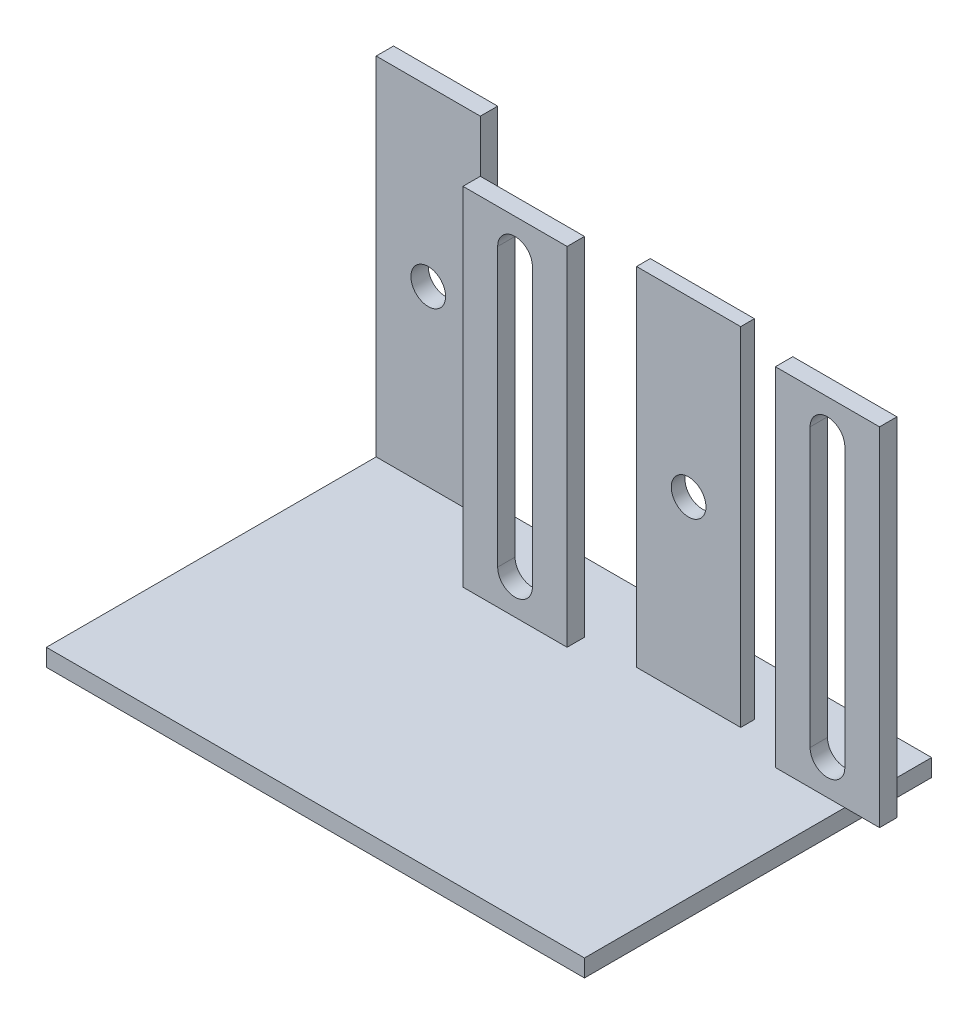
from build123d import *

# Parameters (mm, degrees)
SKETCH1_W           = 310
SKETCH1_H           = 200
BOSS_EXTRUDE1_DEPTH = 10
SKETCH2_W           = 60
SKETCH2_H           = 10
SKETCH2_H_2         = 7.912912389
BOSS_EXTRUDE2_DEPTH = 200
SKETCH3_R           = 10
CUT_EXTRUDE1_DEPTH  = 200


with BuildPart() as part:
    # Sketch1 → Boss-Extrude1 (new body)
    with BuildSketch(Plane(origin=(0, 0, 0), x_dir=(1, 0, 0), z_dir=(0, 1, 0))):
        with Locations((155, 100)):
            Rectangle(SKETCH1_W, SKETCH1_H)
    extrude(amount=BOSS_EXTRUDE1_DEPTH)

    # Sketch2 → Boss-Extrude2 (add)
    with BuildSketch(Plane(origin=(0, 10, 0), x_dir=(1, 0, 0), z_dir=(0, 1, 0))):
        with Locations((30, 195)):
            Rectangle(SKETCH2_W, SKETCH2_H)
        with Locations((120, 155)):
            Rectangle(SKETCH2_W, SKETCH2_H)
        with Locations((300, 155)):
            Rectangle(SKETCH2_W, SKETCH2_H)
        with Locations((210, 163.956456194)):
            Rectangle(SKETCH2_W, SKETCH2_H_2)
    extrude(amount=BOSS_EXTRUDE2_DEPTH)

    # Sketch3 → Cut-Extrude1 (cut)
    with BuildSketch(Plane.XY.offset(-150)):
        with Locations((30, 110)):
            Circle(SKETCH3_R)
        with Locations((210, 110)):
            Circle(SKETCH3_R)
        with BuildLine():
            Line((110, 190), (110, 30))
            ThreePointArc((110, 30), (120, 20), (130, 30))
            Line((130, 30), (130, 190))
            ThreePointArc((130, 190), (120, 200), (110, 190))
        make_face()
        with BuildLine():
            Line((290, 190), (290, 30))
            ThreePointArc((290, 30), (300, 20), (310, 30))
            Line((310, 30), (310, 190))
            ThreePointArc((310, 190), (300, 200), (290, 190))
        make_face()
    extrude(amount=-CUT_EXTRUDE1_DEPTH, mode=Mode.SUBTRACT)


solid = part.part
